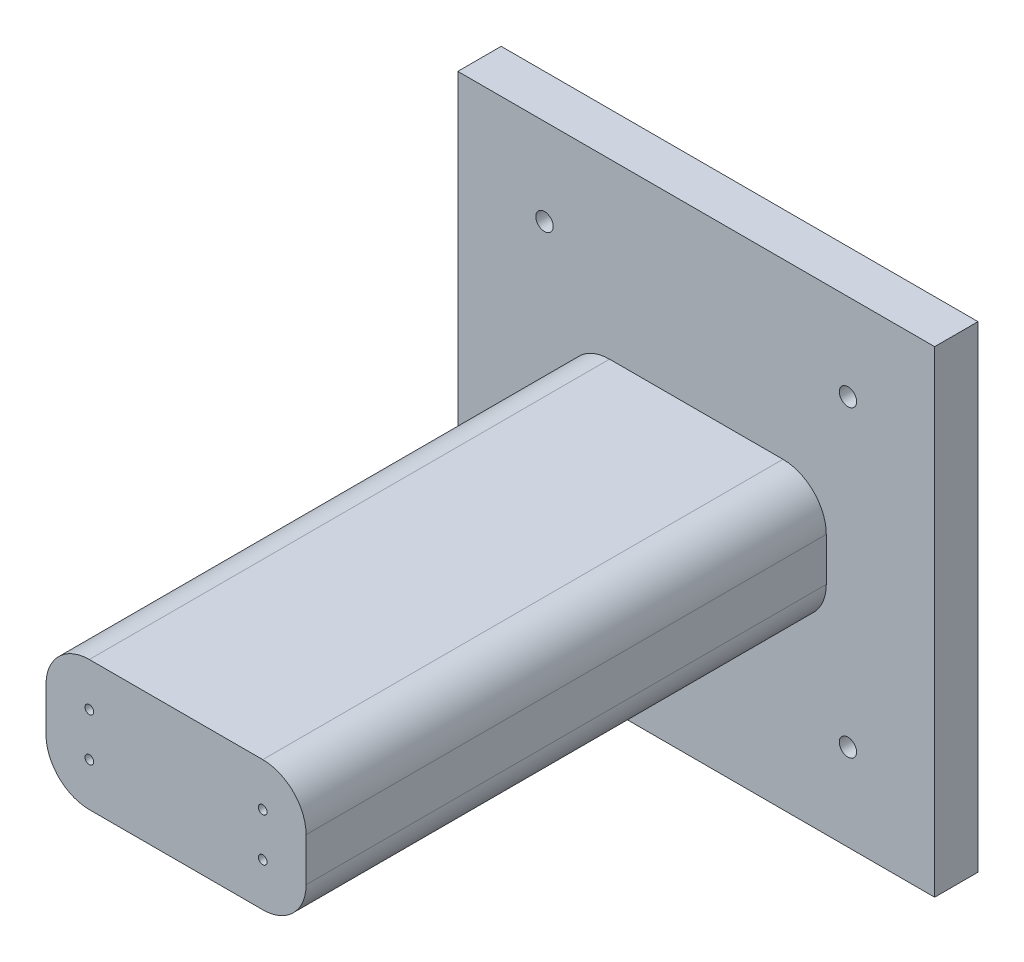
from build123d import *

# Parameters (mm, degrees)
ESQUISSE1_W             = 55
ESQUISSE1_H             = 55
BOSS_EXTRU_1_DEPTH      = 5
ESQUISSE2_W             = 30
ESQUISSE2_H             = 15
BOSS_EXTRU_2_DEPTH      = 60
CONG_2_R                = 5
CONG_3_R                = 5
CONG_4_R                = 5
CONG_5_R                = 5
ENL_V_MAT_EXTRU_1_REACH = 7
ESQUISSE3_R             = 1
ESQUISSE4_R             = 0.5
ENL_V_MAT_EXTRU_2_DEPTH = 2


with BuildPart() as part:
    # Esquisse1 → Boss.-Extru.1 (new body)
    with BuildSketch(Plane.XY):
        Rectangle(ESQUISSE1_W, ESQUISSE1_H)
    extrude(amount=BOSS_EXTRU_1_DEPTH)

    # Esquisse2 → Boss.-Extru.2 (add)
    with BuildSketch(Plane.XY.offset(5)):
        Rectangle(ESQUISSE2_W, ESQUISSE2_H)
    extrude(amount=BOSS_EXTRU_2_DEPTH)

    # Congé2
    cong_2_edges = [part.edges().sort_by_distance(p)[0] for p in [
        (-15, -7.5, 35),
    ]]
    fillet(cong_2_edges, radius=CONG_2_R)

    # Congé3
    cong_3_edges = [part.edges().sort_by_distance(p)[0] for p in [
        (15, 7.5, 35),
    ]]
    fillet(cong_3_edges, radius=CONG_3_R)

    # Congé4
    cong_4_edges = [part.edges().sort_by_distance(p)[0] for p in [
        (15, -7.5, 35),
    ]]
    fillet(cong_4_edges, radius=CONG_4_R)

    # Congé5
    cong_5_edges = [part.edges().sort_by_distance(p)[0] for p in [
        (-15, 7.5, 35),
    ]]
    fillet(cong_5_edges, radius=CONG_5_R)

    # Esquisse3 → Enlèv. mat.-Extru.1 (cut, up to next)
    with BuildSketch(Plane.XY.offset(5), mode=Mode.PRIVATE) as enl_v_mat_extru_1_sk1:
        with Locations((17.5, 17.5)):
            Circle(ESQUISSE3_R)
    enl_v_mat_extru_1_tool1 = extrude(enl_v_mat_extru_1_sk1.sketch, amount=-ENL_V_MAT_EXTRU_1_REACH, mode=Mode.PRIVATE) & part.part
    add(enl_v_mat_extru_1_tool1.solids().sort_by_distance((17.5, 17.5, 5))[0], mode=Mode.SUBTRACT)
    # Esquisse3 → Enlèv. mat.-Extru.1 (cut, up to next)
    with BuildSketch(Plane.XY.offset(5), mode=Mode.PRIVATE) as enl_v_mat_extru_1_sk2:
        with Locations((-17.5, 17.5)):
            Circle(ESQUISSE3_R)
    enl_v_mat_extru_1_tool2 = extrude(enl_v_mat_extru_1_sk2.sketch, amount=-ENL_V_MAT_EXTRU_1_REACH, mode=Mode.PRIVATE) & part.part
    add(enl_v_mat_extru_1_tool2.solids().sort_by_distance((-17.5, 17.5, 5))[0], mode=Mode.SUBTRACT)
    # Esquisse3 → Enlèv. mat.-Extru.1 (cut, up to next)
    with BuildSketch(Plane.XY.offset(5), mode=Mode.PRIVATE) as enl_v_mat_extru_1_sk3:
        with Locations((-17.5, -17.5)):
            Circle(ESQUISSE3_R)
    enl_v_mat_extru_1_tool3 = extrude(enl_v_mat_extru_1_sk3.sketch, amount=-ENL_V_MAT_EXTRU_1_REACH, mode=Mode.PRIVATE) & part.part
    add(enl_v_mat_extru_1_tool3.solids().sort_by_distance((-17.5, -17.5, 5))[0], mode=Mode.SUBTRACT)
    # Esquisse3 → Enlèv. mat.-Extru.1 (cut, up to next)
    with BuildSketch(Plane.XY.offset(5), mode=Mode.PRIVATE) as enl_v_mat_extru_1_sk4:
        with Locations((17.5, -17.5)):
            Circle(ESQUISSE3_R)
    enl_v_mat_extru_1_tool4 = extrude(enl_v_mat_extru_1_sk4.sketch, amount=-ENL_V_MAT_EXTRU_1_REACH, mode=Mode.PRIVATE) & part.part
    add(enl_v_mat_extru_1_tool4.solids().sort_by_distance((17.5, -17.5, 5))[0], mode=Mode.SUBTRACT)

    # Esquisse4 → Enlèv. mat.-Extru.2 (cut)
    with BuildSketch(Plane.XY.offset(65)):
        with Locations((10, -2.5)):
            Circle(ESQUISSE4_R)
        with Locations((10, 2.5)):
            Circle(ESQUISSE4_R)
        with Locations((-10, 2.5)):
            Circle(ESQUISSE4_R)
        with Locations((-10, -2.5)):
            Circle(ESQUISSE4_R)
    extrude(amount=-ENL_V_MAT_EXTRU_2_DEPTH, mode=Mode.SUBTRACT)


solid = part.part
